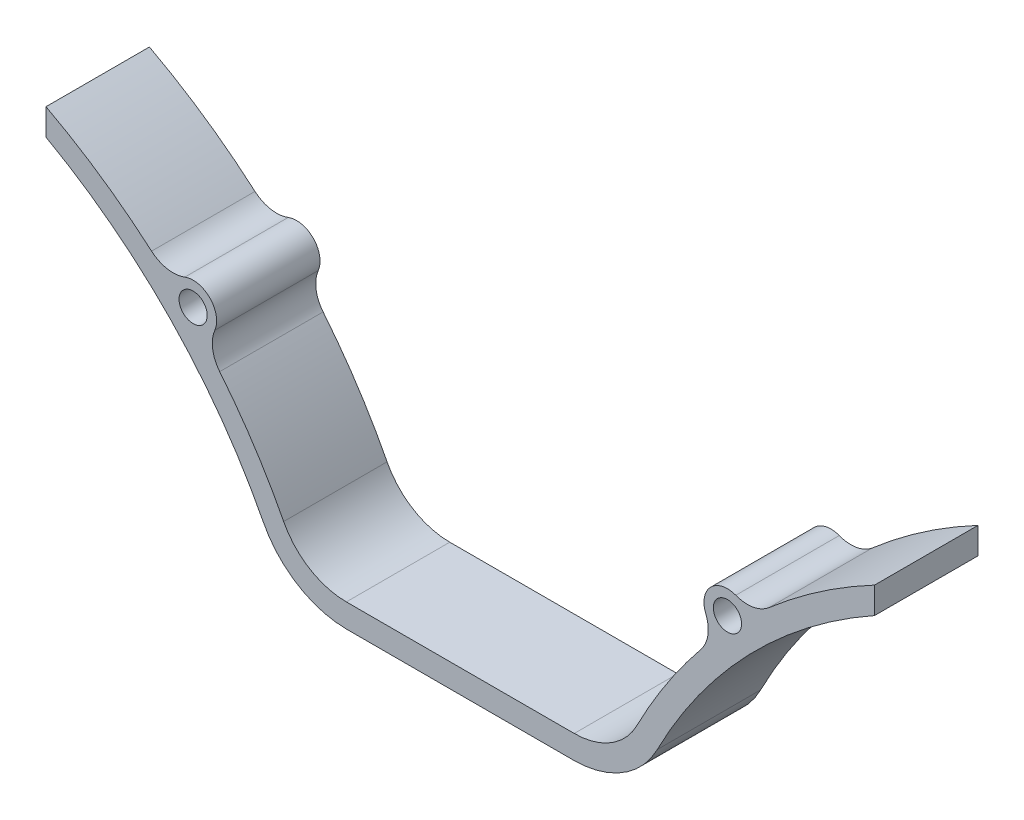
from build123d import *

# Parameters (mm, degrees)
ESBO_O1_R                = 3
RESSALTO_EXTRUS_O1_DEPTH = 22


with BuildPart() as part:
    # Esboço1 → Ressalto-extrusão1 (new body)
    with BuildSketch(Plane.XY):
        with BuildLine():
            Line((-88.131389681, -3.713128135), (-88.131389681, -9.332118261))
            ThreePointArc((-88.131389681, -9.332118261), (-61.477752384, -29.824983348), (-41.890064111, -57.150728877))
            ThreePointArc((-41.890064111, -57.150728877), (-34.522230169, -65.073584532), (-24.106246719, -68))
            Line((-24.106246719, -68), (24.106246719, -68))
            ThreePointArc((24.106246719, -68), (34.522230169, -65.073584532), (41.890064111, -57.150728877))
            ThreePointArc((41.890064111, -57.150728877), (61.477752384, -29.824983348), (88.131389681, -9.332118261))
            Line((88.131389681, -9.332118261), (88.131389681, -3.713128135))
            ThreePointArc((88.131389681, -3.713128135), (76.464485554, -10.766043703), (65.672853174, -19.096766389))
            ThreePointArc((65.672853174, -19.096766389), (62.313137169, -20.69951591), (58.606836852, -20.353343104))
            ThreePointArc((58.606836852, -20.353343104), (53.244280911, -21.549279065), (52.217380785, -26.94675488))
            ThreePointArc((52.217380785, -26.94675488), (52.679803055, -30.640352489), (51.183377998, -34.048755298))
            ThreePointArc((51.183377998, -34.048755298), (50.828817615, -34.48677936), (50.476318173, -34.926463665))
            ThreePointArc((50.476318173, -34.926463665), (43.531544854, -44.57485582), (37.575499443, -54.863046658))
            ThreePointArc((37.575499443, -54.863046658), (32.049623987, -60.805188399), (24.2376364, -63))
            Line((24.2376364, -63), (-24.2376364, -63))
            ThreePointArc((-24.2376364, -63), (-32.049623987, -60.805188399), (-37.575499443, -54.863046658))
            ThreePointArc((-37.575499443, -54.863046658), (-43.531544854, -44.57485582), (-50.476318173, -34.926463665))
            ThreePointArc((-50.476318173, -34.926463665), (-50.828817615, -34.48677936), (-51.183377998, -34.048755298))
            ThreePointArc((-51.183377998, -34.048755298), (-52.679803055, -30.640352489), (-52.217380785, -26.94675488))
            ThreePointArc((-52.217380785, -26.94675488), (-53.244280911, -21.549279065), (-58.606836852, -20.353343104))
            ThreePointArc((-58.606836852, -20.353343104), (-62.313137169, -20.69951591), (-65.672853174, -19.096766389))
            ThreePointArc((-65.672853174, -19.096766389), (-76.464485554, -10.766043703), (-88.131389681, -3.713128135))
        make_face()
        with Locations((-56.834913612, -25.028841797)):
            Circle(ESBO_O1_R, mode=Mode.SUBTRACT)
        with Locations((56.834913612, -25.028841797)):
            Circle(ESBO_O1_R, mode=Mode.SUBTRACT)
    extrude(amount=RESSALTO_EXTRUS_O1_DEPTH)


solid = part.part
